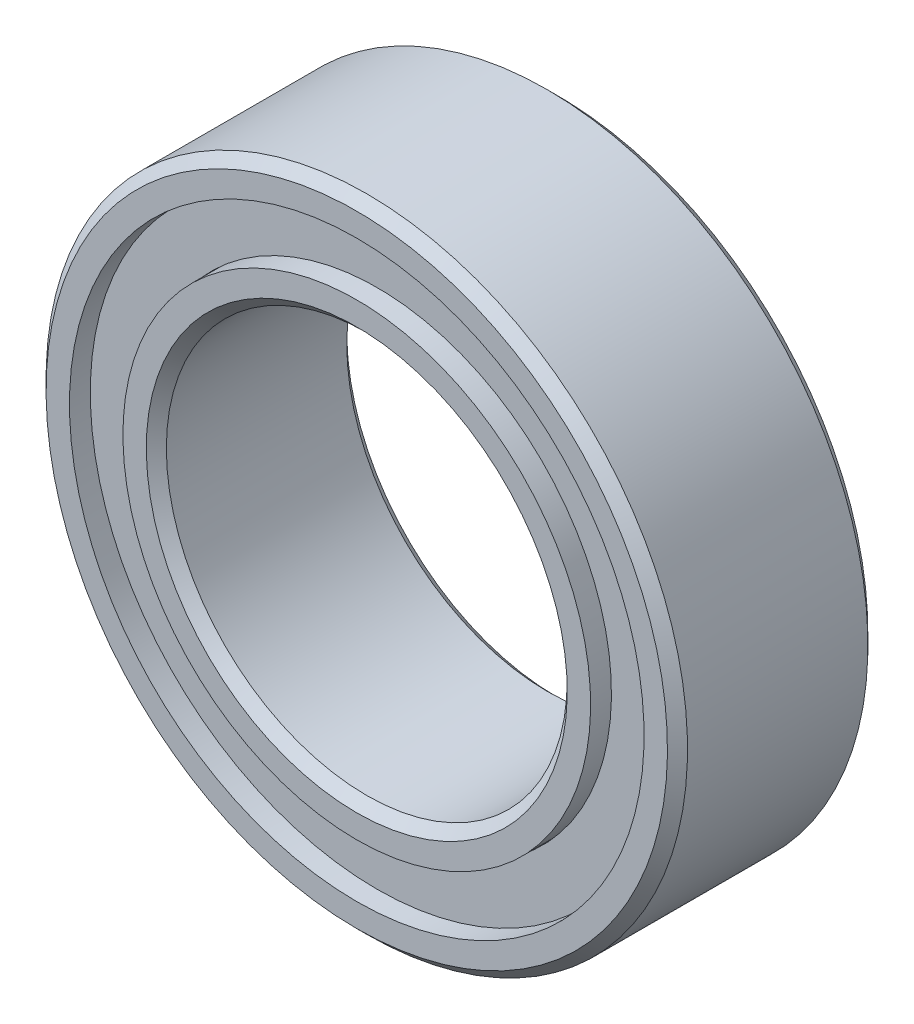
from build123d import *

# Parameters (mm, degrees)
SKETCH5_W         = 0.381
SKETCH5_H         = 2.615866666
CIRPATTERN1_COUNT = 13


with BuildPart() as part:
    # Sketch5 → Revolve1 (revolve)
    with BuildSketch(Plane(origin=(0, 0, 0), x_dir=(0, 0, -1), z_dir=(1, 0, 0))):
        with BuildLine():
            Line((4.5, 16), (-4.5, 16))
            Line((-4.5, 16), (-5, 15.5))
            Line((-5, 15.5), (-5, 14.333333333))
            Line((-5, 14.333333333), (-2.222222222, 14.333333333))
            ThreePointArc((-2.222222222, 14.333333333), (0, 15.591534175), (2.222222222, 14.333333333))
            Line((2.222222222, 14.333333333), (5, 14.333333333))
            Line((5, 14.333333333), (5, 15.5))
            Line((5, 15.5), (4.5, 16))
        make_face()
        with Locations((3.795767088, 13)):
            Rectangle(SKETCH5_W, SKETCH5_H)
        with Locations((-3.795767088, 13)):
            Rectangle(SKETCH5_W, SKETCH5_H)
    revolve(axis=Axis((0, 0, 5), (0, 0, -1)))


with BuildPart() as body_2:
    # Sketch3 → Revolve3 (revolve)
    with BuildSketch(Plane(origin=(0, 0, 0), x_dir=(0, 0, -1), z_dir=(1, 0, 0))):
        with BuildLine():
            Line((-5, 11.666666667), (-2.222222222, 11.666666667))
            ThreePointArc((-2.222222222, 11.666666667), (0, 10.408465825), (2.222222222, 11.666666667))
            Line((2.222222222, 11.666666667), (5, 11.666666667))
            Line((5, 11.666666667), (5, 10.5))
            Line((5, 10.5), (4.5, 10))
            Line((4.5, 10), (-4.5, 10))
            Line((-4.5, 10), (-5, 10.5))
            Line((-5, 10.5), (-5, 11.666666667))
        make_face()
    revolve(axis=Axis((0, 0, 5), (0, 0, -1)))


with BuildPart() as body_3:
    # Sketch4 → Revolve4 (revolve)
    with BuildSketch(Plane(origin=(0, 0, 0), x_dir=(0, 0, -1), z_dir=(1, 0, 0))):
        with BuildLine():
            Line((-2.591534175, 13), (2.591534175, 13))
            ThreePointArc((2.591534175, 13), (0, 15.591534175), (-2.591534175, 13))
        make_face()
    revolve(axis=Axis((0, 13, 2.591534175), (0, 0, -1)))


with BuildPart() as cirpattern1_1:
    # CirPattern1: pattern copy
    add(body_3.part.rotate(Axis((0, 0, 0), (0, 0, 1)), 1 * 360 / CIRPATTERN1_COUNT))


with BuildPart() as cirpattern1_2:
    # CirPattern1: pattern copy
    add(body_3.part.rotate(Axis((0, 0, 0), (0, 0, 1)), 2 * 360 / CIRPATTERN1_COUNT))


with BuildPart() as cirpattern1_3:
    # CirPattern1: pattern copy
    add(body_3.part.rotate(Axis((0, 0, 0), (0, 0, 1)), 3 * 360 / CIRPATTERN1_COUNT))


with BuildPart() as cirpattern1_4:
    # CirPattern1: pattern copy
    add(body_3.part.rotate(Axis((0, 0, 0), (0, 0, 1)), 4 * 360 / CIRPATTERN1_COUNT))


with BuildPart() as cirpattern1_5:
    # CirPattern1: pattern copy
    add(body_3.part.rotate(Axis((0, 0, 0), (0, 0, 1)), 5 * 360 / CIRPATTERN1_COUNT))


with BuildPart() as cirpattern1_6:
    # CirPattern1: pattern copy
    add(body_3.part.rotate(Axis((0, 0, 0), (0, 0, 1)), 6 * 360 / CIRPATTERN1_COUNT))


with BuildPart() as cirpattern1_7:
    # CirPattern1: pattern copy
    add(body_3.part.rotate(Axis((0, 0, 0), (0, 0, 1)), 7 * 360 / CIRPATTERN1_COUNT))


with BuildPart() as cirpattern1_8:
    # CirPattern1: pattern copy
    add(body_3.part.rotate(Axis((0, 0, 0), (0, 0, 1)), 8 * 360 / CIRPATTERN1_COUNT))


with BuildPart() as cirpattern1_9:
    # CirPattern1: pattern copy
    add(body_3.part.rotate(Axis((0, 0, 0), (0, 0, 1)), 9 * 360 / CIRPATTERN1_COUNT))


with BuildPart() as cirpattern1_10:
    # CirPattern1: pattern copy
    add(body_3.part.rotate(Axis((0, 0, 0), (0, 0, 1)), 10 * 360 / CIRPATTERN1_COUNT))


with BuildPart() as cirpattern1_11:
    # CirPattern1: pattern copy
    add(body_3.part.rotate(Axis((0, 0, 0), (0, 0, 1)), 11 * 360 / CIRPATTERN1_COUNT))


with BuildPart() as cirpattern1_12:
    # CirPattern1: pattern copy
    add(body_3.part.rotate(Axis((0, 0, 0), (0, 0, 1)), 12 * 360 / CIRPATTERN1_COUNT))


solid = Compound([part.part, body_2.part, body_3.part, cirpattern1_1.part, cirpattern1_2.part, cirpattern1_3.part, cirpattern1_4.part, cirpattern1_5.part, cirpattern1_6.part, cirpattern1_7.part, cirpattern1_8.part, cirpattern1_9.part, cirpattern1_10.part, cirpattern1_11.part, cirpattern1_12.part])
